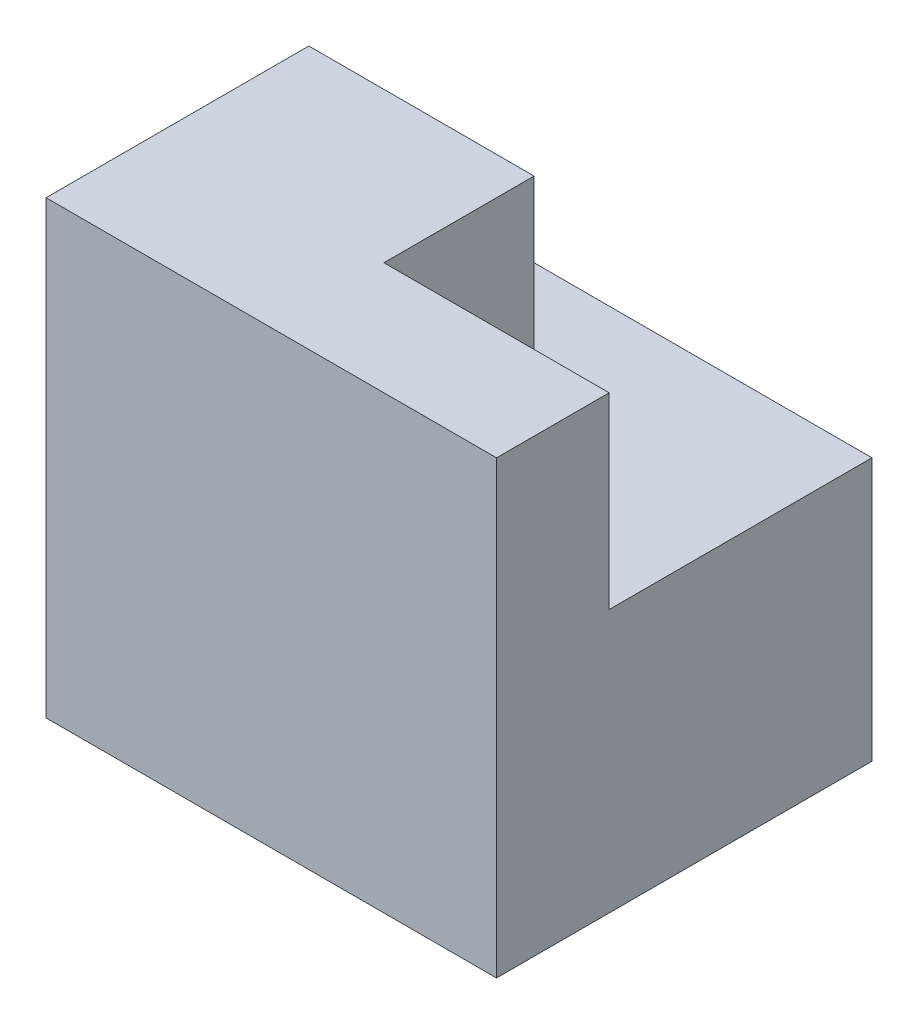
from build123d import *

# Parameters (mm, degrees)
SKETCH1_W           = 6
SKETCH1_H           = 5
BOSS_EXTRUDE1_DEPTH = 6
CUT_EXTRUDE1_DEPTH  = 2.5


with BuildPart() as part:
    # Sketch1 → Boss-Extrude1 (new body)
    with BuildSketch(Plane(origin=(0, 0, 0), x_dir=(1, 0, 0), z_dir=(0, 1, 0))):
        Rectangle(SKETCH1_W, SKETCH1_H)
    extrude(amount=BOSS_EXTRUDE1_DEPTH)

    # Sketch2 → Cut-Extrude1 (cut)
    with BuildSketch(Plane(origin=(0, 6, 0), x_dir=(1, 0, 0), z_dir=(0, 1, 0))):
        Polygon((0, -1), (3, -1), (3, 2.5), (-3, 2.5), (-3, 1), (0, 1), align=None)
    extrude(amount=-CUT_EXTRUDE1_DEPTH, mode=Mode.SUBTRACT)


solid = part.part
